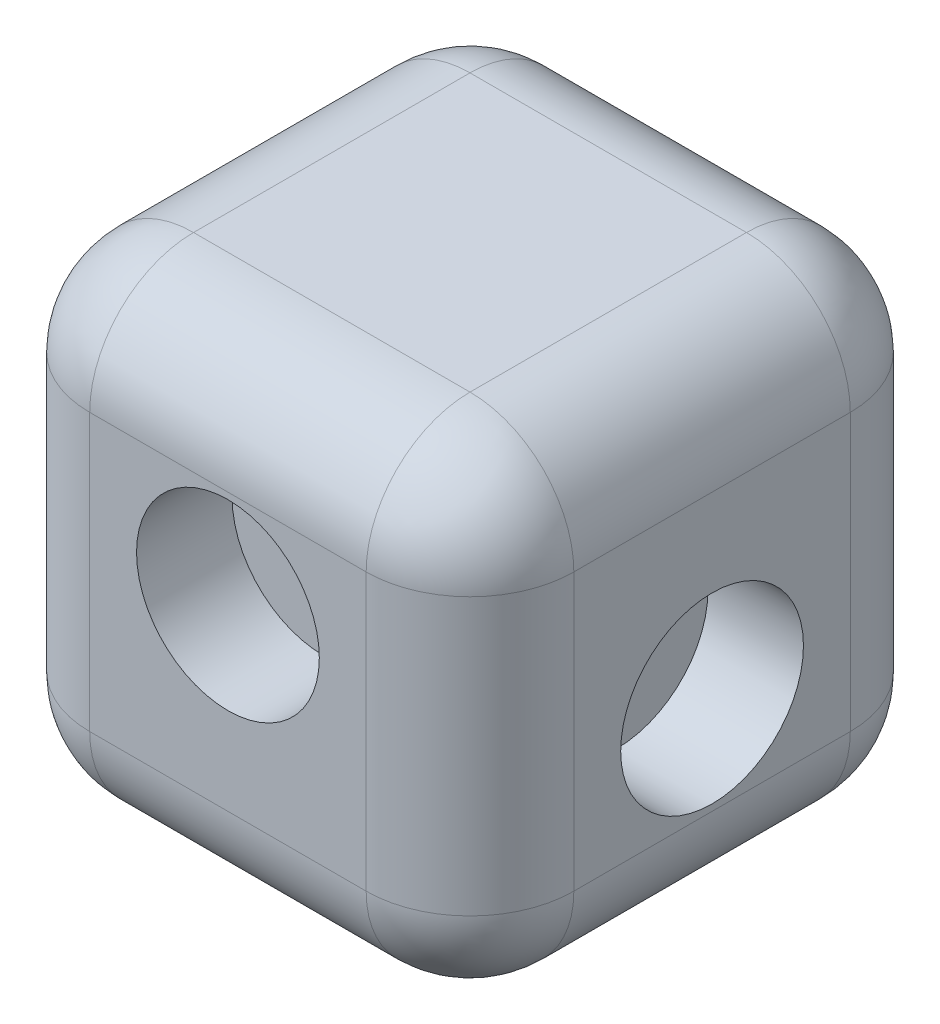
from build123d import *

# Parameters (mm, degrees)
BOSS_EXTRUDE1_DEPTH      = 14.80185
BOSS_EXTRUDE1_DEPTH_BACK = 14.80185
SKETCH1_W                = 29.6037
SKETCH1_H                = 29.6037
FILLET3_R                = 6.35
FILLET4_R                = 6.35
FILLET5_R                = 6.35
FILLET6_R                = 6.35
SKETCH7_R                = 5.588
CUT_EXTRUDE3_DEPTH       = 5.842
CUT_EXTRUDE4_START       = -5.842
SKETCH8_R                = 5.588
CUT_EXTRUDE4_DEPTH       = 5.842
SKETCH3_R                = 5.588
CUT_EXTRUDE5_DEPTH       = 5.842
CUT_EXTRUDE6_START       = -5.842
SKETCH9_R                = 5.588
CUT_EXTRUDE6_DEPTH       = 5.842
FILLET7_R                = 6.35
FILLET8_R                = 6.35


with BuildPart() as part:
    # Sketch1 → Boss-Extrude1 (new, two sides: drawn at the far end of the back side and taken through both)
    with BuildSketch(Plane.XY.offset(-BOSS_EXTRUDE1_DEPTH_BACK)):
        Rectangle(SKETCH1_W, SKETCH1_H)
    extrude(amount=BOSS_EXTRUDE1_DEPTH + BOSS_EXTRUDE1_DEPTH_BACK)

    # Fillet3
    fillet3_edges = [part.edges().sort_by_distance(p)[0] for p in [
        (14.80185, 14.80185, 0),
    ]]
    fillet(fillet3_edges, radius=FILLET3_R)

    # Fillet4
    fillet4_edges = [part.edges().sort_by_distance(p)[0] for p in [
        (-14.80185, 14.80185, 0),
    ]]
    fillet(fillet4_edges, radius=FILLET4_R)

    # Fillet5
    fillet5_edges = [part.edges().sort_by_distance(p)[0] for p in [
        (-14.80185, -14.80185, 0),
    ]]
    fillet(fillet5_edges, radius=FILLET5_R)

    # Fillet6
    fillet6_edges = [part.edges().sort_by_distance(p)[0] for p in [
        (14.80185, -14.80185, 0),
    ]]
    fillet(fillet6_edges, radius=FILLET6_R)

    # Sketch7 → Cut-Extrude3 (cut)
    with BuildSketch(Plane(origin=(0, 0, -14.80185), x_dir=(-1, 0, 0), z_dir=(0, 0, -1))):
        with Locations((0, 2.47015)):
            Circle(SKETCH7_R)
    extrude(amount=-CUT_EXTRUDE3_DEPTH, mode=Mode.SUBTRACT)

    # Sketch8 → Cut-Extrude4 (cut)
    with BuildSketch(Plane.XY.offset(14.80185).offset(CUT_EXTRUDE4_START)):
        with Locations((0, 2.47015)):
            Circle(SKETCH8_R)
    extrude(amount=CUT_EXTRUDE4_DEPTH, mode=Mode.SUBTRACT)

    # Sketch3 → Cut-Extrude5 (cut)
    with BuildSketch(Plane.ZY.offset(14.80185)):
        with Locations((0, -2.47015)):
            Circle(SKETCH3_R)
    extrude(amount=-CUT_EXTRUDE5_DEPTH, mode=Mode.SUBTRACT)

    # Sketch9 → Cut-Extrude6 (cut)
    with BuildSketch(Plane(origin=(14.80185, 0, 0), x_dir=(0, 0, -1), z_dir=(1, 0, 0)).offset(CUT_EXTRUDE6_START)):
        with Locations((0, -2.47015)):
            Circle(SKETCH9_R)
    extrude(amount=CUT_EXTRUDE6_DEPTH, mode=Mode.SUBTRACT)

    # Fillet7
    fillet7_edges = [part.edges().sort_by_distance(p)[0] for p in [
        (0, 14.80185, 14.80185),
    ]]
    fillet(fillet7_edges, radius=FILLET7_R)

    # Fillet8
    fillet8_edges = [part.edges().sort_by_distance(p)[0] for p in [
        (0, 14.80185, -14.80185),
    ]]
    fillet(fillet8_edges, radius=FILLET8_R)


solid = part.part
